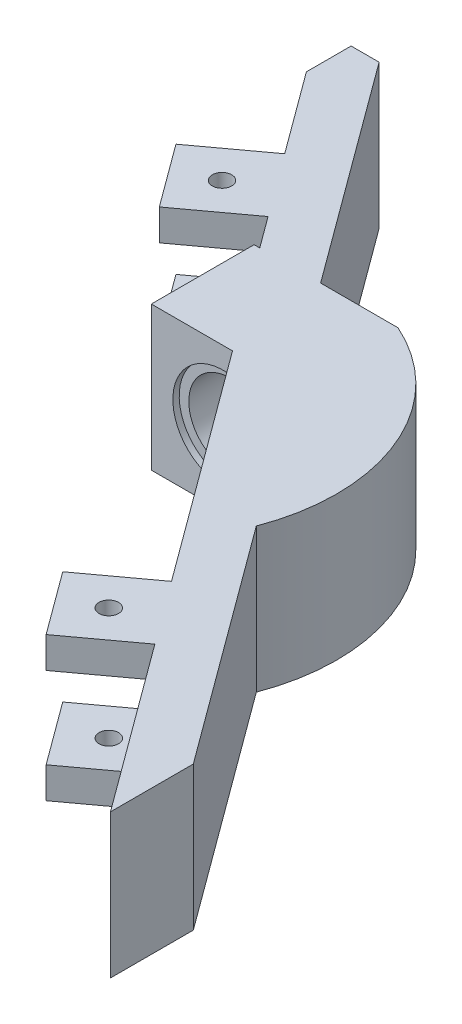
from build123d import *

# Parameters (mm, degrees)
BOSS_EXTRUDE1_DEPTH     = 18.5
SKETCH2_W               = 18.5
SKETCH2_H               = 13.212440144
BOSS_EXTRUDE2_DEPTH     = 9.25
SKETCH4_R               = 5.25
CUT_EXTRUDE1_DEPTH      = 65.978958769
CUT_EXTRUDE1_DEPTH_BACK = 36.75
BOSS_EXTRUDE3_DEPTH     = 9.25
CUT_EXTRUDE3_START      = 5
SKETCH5_R               = 6.5
CUT_EXTRUDE3_DEPTH      = 11.5
SKETCH7_W               = 10
SKETCH7_H               = 4
BOSS_EXTRUDE4_DEPTH     = 10
SKETCH8_W               = 10
SKETCH8_H               = 4
BOSS_EXTRUDE5_DEPTH     = 10
SKETCH9_R               = 1.25
CUT_EXTRUDE4_DEPTH      = 1
CUT_EXTRUDE4_DEPTH_BACK = 19.5
CUT_EXTRUDE5_REACH      = 20.5


with BuildPart() as part:
    # Sketch1 → Boss-Extrude1 (new body)
    with BuildSketch(Plane(origin=(0, 0, 0), x_dir=(1, 0, 0), z_dir=(0, 1, 0))):
        Polygon((0, 0), (0, 5.75), (3.6, 5.75), (77.618084718, -94.978958769), (69.792845102, -94.978958769), align=None)
    extrude(amount=BOSS_EXTRUDE1_DEPTH)

    # Sketch2 → Boss-Extrude2 (add, symmetric)
    with BuildSketch(Plane(origin=(0, 9.25, 0), x_dir=(1, 0, 0), z_dir=(0, 1, 0))):
        with Locations((25.134167429, -29.209707688)):
            Rectangle(SKETCH2_W, SKETCH2_H)
    extrude(amount=BOSS_EXTRUDE2_DEPTH, both=True)

    # Sketch4 → Cut-Extrude1 (cut, two sides)
    with BuildSketch(Plane.XY.offset(30)) as cut_extrude1_sk:
        with Locations((25.134167429, 9.25)):
            Circle(SKETCH4_R)
    extrude(amount=CUT_EXTRUDE1_DEPTH, mode=Mode.SUBTRACT)
    extrude(cut_extrude1_sk.sketch, amount=-CUT_EXTRUDE1_DEPTH_BACK, mode=Mode.SUBTRACT)

    # Sketch6 → Boss-Extrude3 (add, symmetric)
    with BuildSketch(Plane(origin=(0, 9.25, 0), x_dir=(1, 0, 0), z_dir=(0, 1, 0))):
        with BuildLine():
            Line((34.384167429, -22.603487616), (34.143652987, -35.81592776))
            Line((34.143652987, -35.81592776), (47.347337909, -53.784420719))
            ThreePointArc((47.347337909, -53.784420719), (47.065802481, -35.616343599), (34.384167429, -22.603487616))
        make_face()
    extrude(amount=BOSS_EXTRUDE3_DEPTH, both=True)

    # Sketch5 → Cut-Extrude3 (cut)
    with BuildSketch(Plane.XY.offset(30).offset(CUT_EXTRUDE3_START)):
        with Locations((25.150542623, 9.25)):
            Circle(SKETCH5_R)
    extrude(amount=CUT_EXTRUDE3_DEPTH, mode=Mode.SUBTRACT)

    # Sketch7 → Boss-Extrude4 (add)
    with BuildSketch(Plane(origin=(0, 0, 0), x_dir=(0.592144678, 0, 0.80583167), z_dir=(-0.80583167, 0, 0.592144678))):
        with Locations((18.049887406, 2)):
            Rectangle(SKETCH7_W, SKETCH7_H)
        with Locations((18.049887406, 16.5)):
            Rectangle(SKETCH7_W, SKETCH7_H)
    extrude(amount=BOSS_EXTRUDE4_DEPTH)

    # Sketch8 → Boss-Extrude5 (add)
    with BuildSketch(Plane(origin=(0, 0, 0), x_dir=(0.592144678, 0, 0.80583167), z_dir=(-0.80583167, 0, 0.592144678))):
        with Locations((86.155216017, 2)):
            Rectangle(SKETCH8_W, SKETCH8_H)
        with Locations((86.155216017, 16.5)):
            Rectangle(SKETCH8_W, SKETCH8_H)
    extrude(amount=BOSS_EXTRUDE5_DEPTH)

    # Sketch9 → Cut-Extrude4 (cut, two sides)
    with BuildSketch(Plane(origin=(0, 18.5, 0), x_dir=(1, 0, 0), z_dir=(0, 1, 0))) as cut_extrude4_sk:
        with Locations((6.65898641, -17.505894303)):
            Circle(SKETCH9_R)
        with Locations((46.987194274, -72.387325004)):
            Circle(SKETCH9_R)
    extrude(amount=CUT_EXTRUDE4_DEPTH, mode=Mode.SUBTRACT)
    extrude(cut_extrude4_sk.sketch, amount=-CUT_EXTRUDE4_DEPTH_BACK, mode=Mode.SUBTRACT)

    # Sketch10 → Cut-Extrude5 (cut, up to next)
    with BuildSketch(Plane(origin=(0, 18.5, 0), x_dir=(1, 0, 0), z_dir=(0, 1, 0)), mode=Mode.PRIVATE) as cut_extrude5_sk1:
        Polygon((69.792845102, -84.329828334), (69.792845102, -94.978958769), (77.618084718, -94.978958769), align=None)
    cut_extrude5_tool1 = extrude(cut_extrude5_sk1.sketch, amount=-CUT_EXTRUDE5_REACH, mode=Mode.PRIVATE) & part.part
    add(cut_extrude5_tool1.solids().sort_by_distance((72.401258, 18.5, 91.429249))[0], mode=Mode.SUBTRACT)


solid = part.part
